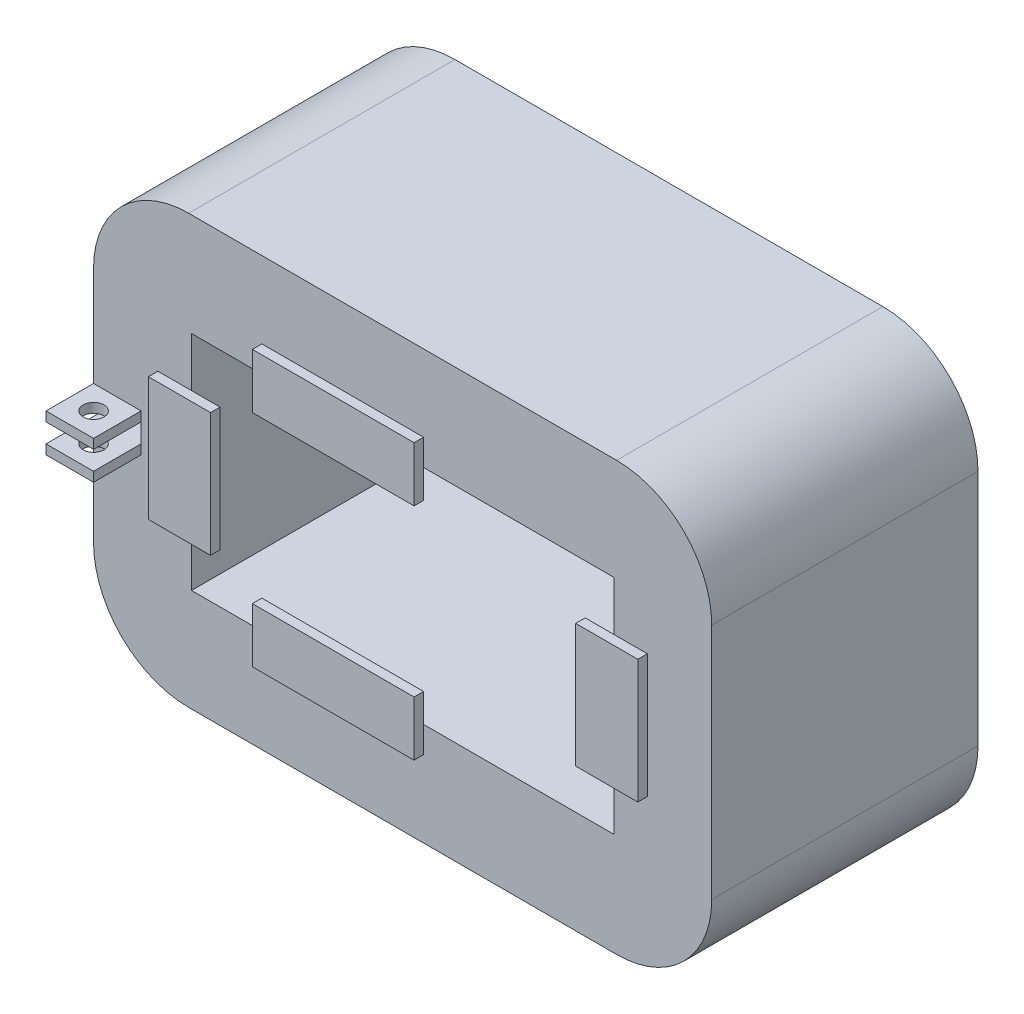
from build123d import *

# Parameters (mm, degrees)
SKETCH_1_W               = 65
SKETCH_1_H               = 45
EXTRUDE_1_DEPTH          = 28
SKETCH_2_W               = 44.4
SKETCH_2_H               = 23.4
CUT_EXTRUDE_1_DEPTH      = 39
FILLET_1_R               = 10
FILLET_2_R               = 10
FILLET_3_R               = 10
FILLET_4_R               = 10
EXTRUDE_6_DEPTH          = 1
EXTRUDE_6_2_DEPTH        = 1
EXTRUDE_6_3_DEPTH        = 1
SKETCH_10_W              = 17
SKETCH_10_H              = 5.754584259
EXTRUDE_6_4_DEPTH        = 1
SKETCH_19_W              = 5
SKETCH_19_H              = 30.097075205
CUT_EXTRUDE_3_DEPTH      = 1
CUT_EXTRUDE_3_DEPTH_BACK = 1
SKETCH_20_W              = 5
SKETCH_20_H              = 1
EXTRUDE_12_DEPTH         = 5
SKETCH_21_W              = 5
SKETCH_21_H              = 1
EXTRUDE_13_DEPTH         = 5
SKETCH_22_R              = 1.1
CUT_EXTRUDE_4_DEPTH      = 5
CUT_EXTRUDE_4_DEPTH_BACK = 5


with BuildPart() as part:
    # 草圖1 → 填料-伸長1 (new body)
    with BuildSketch(Plane.XY):
        with Locations((-27.434655272, 0)):
            Rectangle(SKETCH_1_W, SKETCH_1_H)
    extrude(amount=EXTRUDE_1_DEPTH)

    # 草圖2 → 除料-伸長1 (cut)
    with BuildSketch(Plane.XY):
        with Locations((-27.434655272, 0)):
            Rectangle(SKETCH_2_W, SKETCH_2_H)
    extrude(amount=CUT_EXTRUDE_1_DEPTH, mode=Mode.SUBTRACT)

    # 圓角1
    fillet_1_edges = [part.edges().sort_by_distance(p)[0] for p in [
        (-59.934655272, -22.5, 14),
    ]]
    fillet(fillet_1_edges, radius=FILLET_1_R)

    # 圓角2
    fillet_2_edges = [part.edges().sort_by_distance(p)[0] for p in [
        (-59.934655272, 22.5, 14),
    ]]
    fillet(fillet_2_edges, radius=FILLET_2_R)

    # 圓角3
    fillet_3_edges = [part.edges().sort_by_distance(p)[0] for p in [
        (5.065344728, 22.5, 14),
    ]]
    fillet(fillet_3_edges, radius=FILLET_3_R)

    # 圓角4
    fillet_4_edges = [part.edges().sort_by_distance(p)[0] for p in [
        (5.065344728, -22.5, 14),
    ]]
    fillet(fillet_4_edges, radius=FILLET_4_R)

    # 草圖19 → 除料-伸長3 (cut, two sides)
    with BuildSketch(Plane(origin=(0, 0, 0), x_dir=(1, 0, 0), z_dir=(0, 1, 0))) as cut_extrude_3_sk:
        with Locations((-57.434655272, -13.951462398)):
            Rectangle(SKETCH_19_W, SKETCH_19_H)
    extrude(amount=CUT_EXTRUDE_3_DEPTH, mode=Mode.SUBTRACT)
    extrude(cut_extrude_3_sk.sketch, amount=-CUT_EXTRUDE_3_DEPTH_BACK, mode=Mode.SUBTRACT)

    # 草圖20 → 填料-伸長12 (add)
    with BuildSketch(Plane.XY):
        with Locations((-57.434655272, 1.5)):
            Rectangle(SKETCH_20_W, SKETCH_20_H)
        with Locations((-57.434655272, -1.5)):
            Rectangle(SKETCH_20_W, SKETCH_20_H)
    extrude(amount=-EXTRUDE_12_DEPTH)

    # 草圖21 → 填料-伸長13 (add)
    with BuildSketch(Plane.XY.offset(28)):
        with Locations((-57.434655272, 1.5)):
            Rectangle(SKETCH_21_W, SKETCH_21_H)
        with Locations((-57.434655272, -1.5)):
            Rectangle(SKETCH_21_W, SKETCH_21_H)
    extrude(amount=EXTRUDE_13_DEPTH)

    # 草圖22 → 除料-伸長4 (cut, two sides)
    with BuildSketch(Plane(origin=(0, 0, 0), x_dir=(1, 0, 0), z_dir=(0, 1, 0))) as cut_extrude_4_sk:
        with Locations((-57.434655272, -30.5)):
            Circle(SKETCH_22_R)
        with Locations((-57.434655272, 2.5)):
            Circle(SKETCH_22_R)
    extrude(amount=CUT_EXTRUDE_4_DEPTH, mode=Mode.SUBTRACT)
    extrude(cut_extrude_4_sk.sketch, amount=-CUT_EXTRUDE_4_DEPTH_BACK, mode=Mode.SUBTRACT)


with BuildPart() as body_2:
    # 草圖10 → 填料-伸長6 (new body)
    with BuildSketch(Plane.XY.offset(29)):
        Polygon((-49.634655272, 6.5), (-53.165057103, 6.5), (-53.165057103, -6.5), (-46.634655272, -6.5), (-46.634655272, 6.5), align=None)
    extrude(amount=-EXTRUDE_6_DEPTH)


with BuildPart() as body_3:
    # 草圖10 → Extrude 6 2 (new body)
    with BuildSketch(Plane.XY.offset(29)):
        Polygon((-42.234655272, -11.7), (-42.234655272, -8.7), (-25.234655272, -8.7), (-25.234655272, -14.454584259), (-42.234655272, -14.454584259), align=None)
    extrude(amount=-EXTRUDE_6_2_DEPTH)


with BuildPart() as body_4:
    # 草圖10 → Extrude 6 3 (new body)
    with BuildSketch(Plane.XY.offset(29)):
        Polygon((-8.234655272, 6.5), (-8.234655272, -6.5), (-5.234655272, -6.5), (-1.70425344, -6.5), (-1.70425344, 6.5), align=None)
    extrude(amount=-EXTRUDE_6_3_DEPTH)


with BuildPart() as body_5:
    # 草圖10 → Extrude 6 4 (new body)
    with BuildSketch(Plane.XY.offset(29)):
        with Locations((-33.734655272, 11.57729213)):
            Rectangle(SKETCH_10_W, SKETCH_10_H)
    extrude(amount=-EXTRUDE_6_4_DEPTH)


solid = Compound([part.part, body_2.part, body_3.part, body_4.part, body_5.part])
